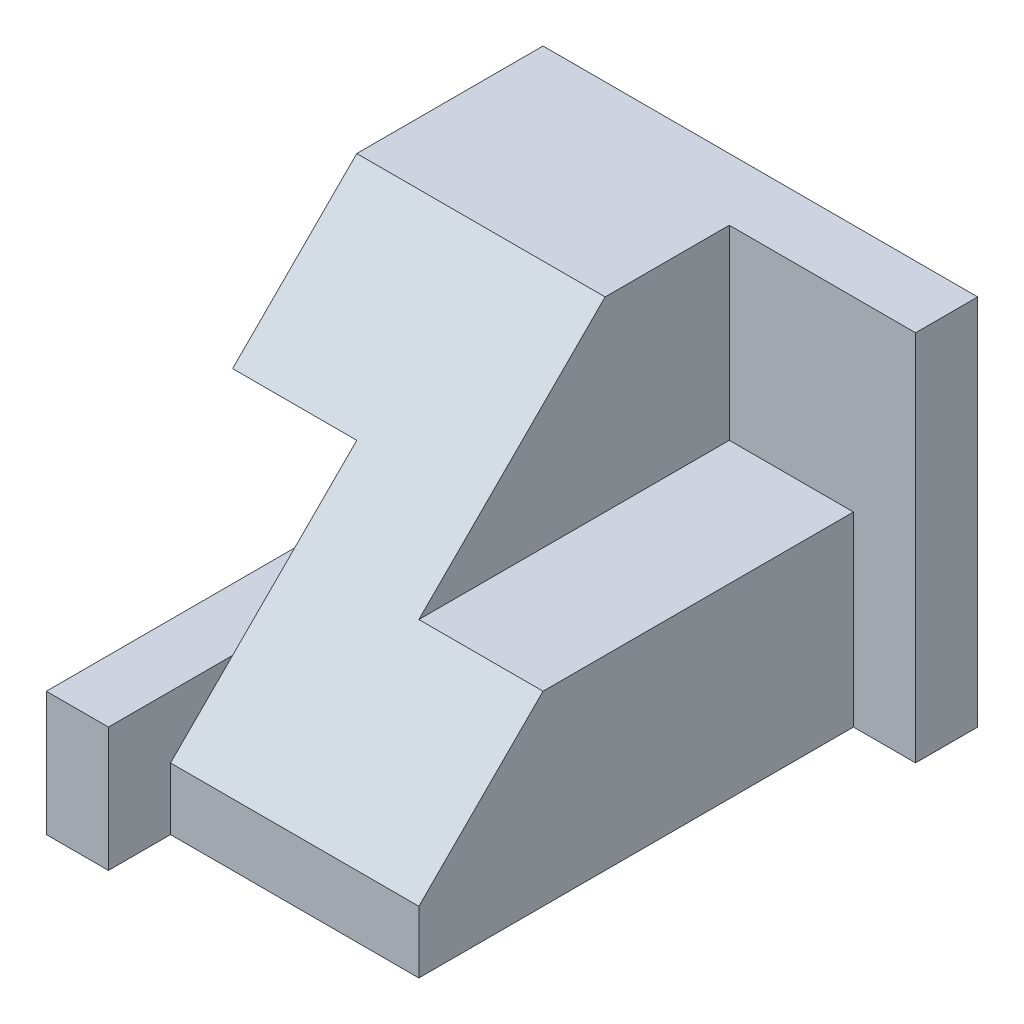
from build123d import *

# Parameters (mm, degrees)
SKETCH1_W           = 7
SKETCH1_H           = 6
BOSS_EXTRUDE1_DEPTH = 9
SKETCH2_W           = 3
SKETCH2_H           = 5
CUT_EXTRUDE1_DEPTH  = 3
CUT_EXTRUDE2_DEPTH  = 7
SKETCH4_W           = 1
SKETCH4_H           = 2
BOSS_EXTRUDE2_DEPTH = 1
CUT_EXTRUDE3_DEPTH  = 10
CUT_EXTRUDE5_DEPTH  = 4
CUT_EXTRUDE6_DEPTH  = 3


with BuildPart() as part:
    # Sketch1 → Boss-Extrude1 (new body)
    with BuildSketch(Plane.XY):
        Rectangle(SKETCH1_W, SKETCH1_H)
    extrude(amount=BOSS_EXTRUDE1_DEPTH)

    # Sketch2 → Cut-Extrude1 (cut)
    with BuildSketch(Plane(origin=(0, 3, 0), x_dir=(1, 0, 0), z_dir=(0, 1, 0))):
        with Locations((2, -3.5)):
            Rectangle(SKETCH2_W, SKETCH2_H)
    extrude(amount=-CUT_EXTRUDE1_DEPTH, mode=Mode.SUBTRACT)

    # Sketch3 → Cut-Extrude2 (cut, through all)
    with BuildSketch(Plane(origin=(0, 3, 0), x_dir=(1, 0, 0), z_dir=(0, 1, 0))):
        Polygon((3.5, -1), (2.5, -1), (2.5, -8), (-2.5, -8), (-2.5, -9), (3.5, -9), align=None)
    extrude(amount=-CUT_EXTRUDE2_DEPTH, mode=Mode.SUBTRACT)

    # Sketch4 → Boss-Extrude2 (add)
    with BuildSketch(Plane(origin=(-2.5, 0, 0), x_dir=(0, 0, -1), z_dir=(1, 0, 0))):
        with Locations((-8.5, -2)):
            Rectangle(SKETCH4_W, SKETCH4_H)
    extrude(amount=BOSS_EXTRUDE2_DEPTH)

    # Sketch5 → Cut-Extrude3 (cut, through all)
    with BuildSketch(Plane.XY.offset(9)):
        Polygon((-3.5, 1), (-1.5, 1), (-1.5, -1), (-2.5, -1), (-2.5, -3), (-3.5, -3), align=None)
    extrude(amount=-CUT_EXTRUDE3_DEPTH, mode=Mode.SUBTRACT)

    # Sketch6 → Cut-Extrude5 (cut)
    with BuildSketch(Plane(origin=(2.5, 0, 0), x_dir=(0, 0, -1), z_dir=(1, 0, 0))):
        Polygon((-3, 3), (-8, -2), (-8, 1), (-9, 1), (-9, 3), align=None)
    extrude(amount=-CUT_EXTRUDE5_DEPTH, mode=Mode.SUBTRACT)

    # Sketch8 → Cut-Extrude6 (cut, through all)
    with BuildSketch(Plane(origin=(-1.5, 0, 0), x_dir=(0, 0, -1), z_dir=(1, 0, 0))):
        Polygon((-5, 1), (-3, 3), (-9, 3), (-9, 1), align=None)
    extrude(amount=-CUT_EXTRUDE6_DEPTH, mode=Mode.SUBTRACT)


solid = part.part
